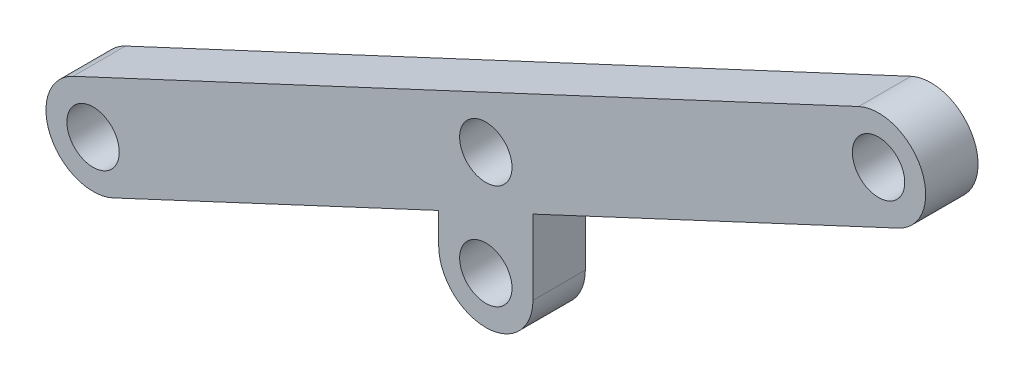
from build123d import *

# Parameters (mm, degrees)
SKETCH_1_R      = 2.5
EXTRUDE_1_DEPTH = 2.5
SKETCH_2_R      = 2.5
EXTRUDE_2_DEPTH = 5


with BuildPart() as part:
    # 草图1 → 凸台-拉伸1 (new body, symmetric)
    with BuildSketch(Plane.XY):
        with BuildLine():
            Line((-4.5, -5), (-4.5, 5))
            ThreePointArc((-4.5, 5), (0, 9.5), (4.5, 5))
            Line((4.5, 5), (4.5, -5))
            ThreePointArc((4.5, -5), (0, -9.5), (-4.5, -5))
        make_face()
        with Locations((0, 5)):
            Circle(SKETCH_1_R, mode=Mode.SUBTRACT)
        with Locations((0, -5)):
            Circle(SKETCH_1_R, mode=Mode.SUBTRACT)
    extrude(amount=EXTRUDE_1_DEPTH, both=True)

    # 草图2 → 凸台-拉伸2 (add)
    with BuildSketch(Plane.XY.offset(2.5)):
        with BuildLine():
            Line((-39.402984594, -8.42217587), (35.597015406, 26.57782413))
            ThreePointArc((35.597015406, 26.57782413), (41.57782413, 24.402984594), (39.402984594, 18.42217587))
            Line((39.402984594, 18.42217587), (-35.597015406, -16.57782413))
            ThreePointArc((-35.597015406, -16.57782413), (-41.57782413, -14.402984594), (-39.402984594, -8.42217587))
        make_face()
        with Locations((-37.5, -12.5)):
            Circle(SKETCH_2_R, mode=Mode.SUBTRACT)
        with Locations((37.5, 22.5)):
            Circle(SKETCH_2_R, mode=Mode.SUBTRACT)
        with Locations((0, 5)):
            Circle(SKETCH_2_R, mode=Mode.SUBTRACT)
    extrude(amount=-EXTRUDE_2_DEPTH)


solid = part.part
